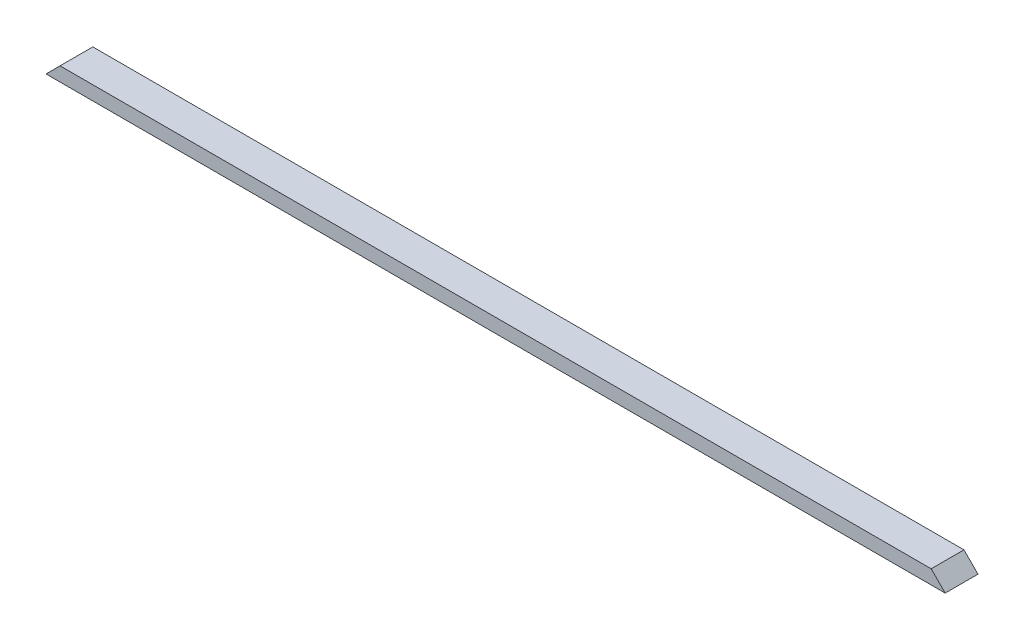
from build123d import *

# Parameters (mm, degrees)
SKETCH1_W           = 2438.4
SKETCH1_H           = 88.9
BOSS_EXTRUDE1_DEPTH = 38.1
CUT_EXTRUDE1_DEPTH  = 89.9


with BuildPart() as part:
    # Sketch1 → Boss-Extrude1 (new body)
    with BuildSketch(Plane(origin=(0, 0, 0), x_dir=(1, 0, 0), z_dir=(0, 1, 0))):
        with Locations((1219.2, 44.45)):
            Rectangle(SKETCH1_W, SKETCH1_H)
    extrude(amount=BOSS_EXTRUDE1_DEPTH)

    # Sketch2 → Cut-Extrude1 (cut, through all)
    with BuildSketch(Plane.XY):
        Polygon((0, 0), (38.1, 38.1), (0, 38.1), align=None)
        Polygon((2438.4, 0), (2438.4, 38.1), (2400.3, 38.1), align=None)
    extrude(amount=-CUT_EXTRUDE1_DEPTH, mode=Mode.SUBTRACT)


solid = part.part
